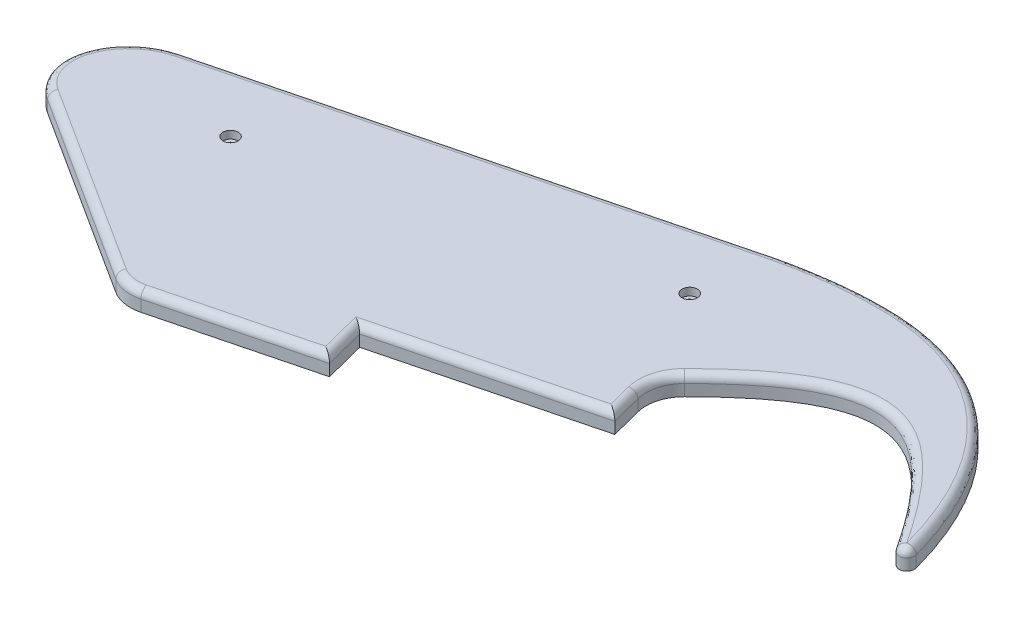
from build123d import *

# Parameters (mm, degrees)
BOSS_EXTRUDE1_DEPTH = 5
FILLET1_R           = 2
CUT_EXTRUDE1_REACH  = 7
SKETCH2_R           = 1
SKETCH3_R           = 2
CUT_EXTRUDE2_DEPTH  = 2


with BuildPart() as part:
    # Sketch1 → Boss-Extrude1 (new body)
    with BuildSketch(Plane(origin=(0, 0, 0), x_dir=(1, 0, 0), z_dir=(0, 1, 0))):
        with BuildLine():
            Line((306.773541151, -446.08088768), (304.040992645, -435.425692765))
            Line((304.040992645, -435.425692765), (357.316967216, -421.762950233))
            Line((357.316967216, -421.762950233), (355.23171374, -413.63179275))
            ThreePointArc((355.23171374, -413.63179275), (355.273716975, -408.505141033), (357.850721539, -404.073056919))
            add(Edge.make_bspline(
                [(357.850721539, -404.073056919), (386.472662421, -375.479710436), (401.109006011, -380.481946645), (423.626564821, -414.223232187)],
                knots=[0.040011627, 0.040011627, 0.040011627, 0.040011627, 0.916017128, 0.916017128, 0.916017128, 0.916017128], degree=3))
            ThreePointArc((423.626564821, -414.223232187), (426.118577589, -414.933385982), (427.219954499, -412.587876452))
            add(Edge.make_bspline(
                [(427.219954499, -412.587876452), (419.112300167, -382.794315145), (392.60093738, -356.855706867), (352.652680327, -362.29898708), (342.660570681, -364.612359329)],
                knots=[0.005774044, 0.005774044, 0.005774044, 0.005774044, 0.670804944, 1, 1, 1, 1], degree=3))
            Line((342.660570681, -364.612359329), (218.087436188, -396.559417581))
            add(Edge.make_bspline(
                [(218.087436188, -396.559417581), (215.985721411, -397.098407025), (214.024827527, -398.128946484), (212.08163804, -399.150181473), (210.415707145, -400.58202679), (208.735394171, -402.026233311), (207.459609752, -403.784190004), (206.152389863, -405.585462946), (205.369272041, -407.579797671), (204.543481725, -409.682804724), (204.368372714, -411.826216521), (204.184545672, -414.076340871), (204.734125539, -416.165983668), (205.301931856, -418.324928079), (206.597315727, -420.10032807), (207.894346144, -421.877984749), (209.791348209, -423.091930999)],
                knots=[0, 0, 0, 0.125, 0.125, 0.25, 0.25, 0.375, 0.375, 0.5, 0.5, 0.625, 0.625, 0.75, 0.75, 0.875, 0.875, 1, 1, 1], degree=2))
            Line((209.791348209, -423.091930999), (259.521688737, -454.915808027))
            ThreePointArc((259.521688737, -454.915808027), (263.327402125, -456.366508109), (267.395935235, -456.179362565))
            Line((267.395935235, -456.179362565), (306.773541151, -446.08088768))
        make_face()
    extrude(amount=BOSS_EXTRUDE1_DEPTH)

    # Fillet1
    fillet1_edges = [part.edges().sort_by_distance(p)[0] for p in [
        (305.407266898, 5, 440.753290222),
        (287.084738193, 5, 451.130125122),
        (263.327402125, 5, 456.366508109),
        (234.656518473, 5, 439.003869513),
        (205.35390653, 5, 407.619076414),
        (280.374003434, 5, 380.585888455),
        (393.811057272, 5, 385.93635723),
        (426.118577589, 5, 414.933385982),
        (393.811057272, 5, 385.93635723),
        (355.273716975, 5, 408.505141033),
        (356.274340478, 5, 417.697371492),
        (330.67897993, 5, 428.594321499),
    ]]
    fillet(fillet1_edges, radius=FILLET1_R)

    # Sketch2 → Cut-Extrude1 (cut, up to next)
    with BuildSketch(Plane.XZ, mode=Mode.PRIVATE) as cut_extrude1_sk1:
        with Locations((340.092739476, 384.885730681)):
            Circle(SKETCH2_R)
    cut_extrude1_tool1 = extrude(cut_extrude1_sk1.sketch, amount=-CUT_EXTRUDE1_REACH, mode=Mode.PRIVATE) & part.part
    add(cut_extrude1_tool1.solids().sort_by_distance((340.092739, 0, 384.885731))[0], mode=Mode.SUBTRACT)
    # Sketch2 → Cut-Extrude1 (cut, up to next)
    with BuildSketch(Plane.XZ, mode=Mode.PRIVATE) as cut_extrude1_sk2:
        with Locations((244.195985248, 409.47866724)):
            Circle(SKETCH2_R)
    cut_extrude1_tool2 = extrude(cut_extrude1_sk2.sketch, amount=-CUT_EXTRUDE1_REACH, mode=Mode.PRIVATE) & part.part
    add(cut_extrude1_tool2.solids().sort_by_distance((244.195985, 0, 409.478667))[0], mode=Mode.SUBTRACT)

    # Sketch3 → Cut-Extrude2 (cut)
    with BuildSketch(Plane(origin=(0, 5, 0), x_dir=(1, 0, 0), z_dir=(0, 1, 0))):
        with Locations((244.195985248, -409.47866724)):
            Circle(SKETCH3_R)
        with Locations((340.092739476, -384.885730681)):
            Circle(SKETCH3_R)
    extrude(amount=-CUT_EXTRUDE2_DEPTH, mode=Mode.SUBTRACT)


solid = part.part
